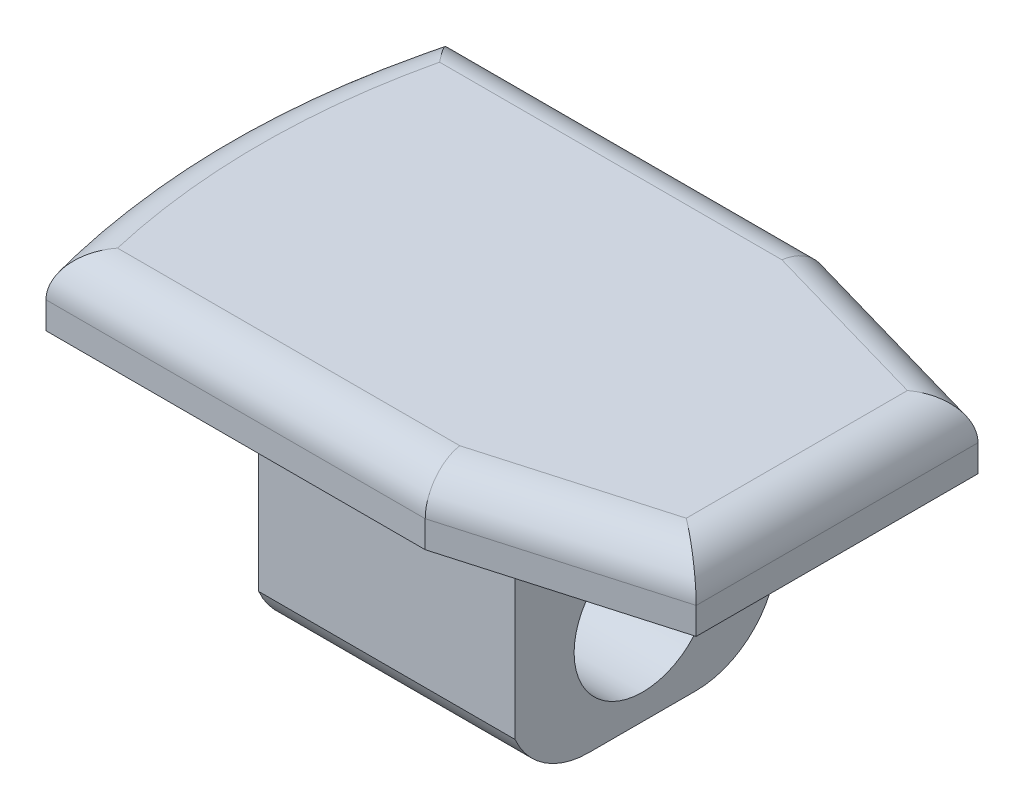
from build123d import *

# Parameters (mm, degrees)
BOSS_EXTRUDE1_DEPTH      = 2.5
BOSS_EXTRUDE2_DEPTH      = 1.5
BOSS_EXTRUDE2_DEPTH_BACK = 1.5
FILLET1_R                = 1.5
SKETCH5_W                = 9.8
SKETCH5_H                = 10
BOSS_EXTRUDE3_DEPTH      = 7.5
SKETCH6_R                = 2.55
CUT_EXTRUDE1_DEPTH       = 8
FILLET2_R                = 3
SKETCH8_R                = 3
SKETCH8_R_2              = 2.6
BOSS_EXTRUDE4_DEPTH      = 0.8
SKETCH9_W                = 0.75667274
SKETCH9_H                = 5.4
CUT_EXTRUDE3_DEPTH       = 3
SKETCH10_R               = 3
CUT_EXTRUDE4_DEPTH       = 3
CUT_EXTRUDE5_DEPTH       = 10


with BuildPart() as part:
    # Sketch1 → Boss-Extrude1 (new body)
    with BuildSketch(Plane(origin=(0, 0, 0), x_dir=(1, 0, 0), z_dir=(0, 1, 0))):
        with BuildLine():
            Line((-20.209371097, 50.622586501), (-32.257467167, 50.622586501))
            ThreePointArc((-32.257467167, 50.622586501), (-33.362688598, 43.122586501), (-32.257467167, 35.622586501))
            Line((-32.257467167, 35.622586501), (-20.209371097, 35.622586501))
            Line((-20.209371097, 35.622586501), (-12.362688598, 37.872586501))
            Line((-12.362688598, 37.872586501), (-12.362688598, 48.372586501))
            Line((-12.362688598, 48.372586501), (-20.209371097, 50.622586501))
        make_face()
        with BuildLine():
            Line((-32.257467167, 50.622586501), (-34.339530518, 50.622586501))
            ThreePointArc((-34.339530518, 50.622586501), (-35.362688598, 43.122586501), (-34.339530518, 35.622586501))
            Line((-34.339530518, 35.622586501), (-32.257467167, 35.622586501))
            ThreePointArc((-32.257467167, 35.622586501), (-33.362688598, 43.122586501), (-32.257467167, 50.622586501))
        make_face()
    extrude(amount=BOSS_EXTRUDE1_DEPTH)

    # Sketch4 → Boss-Extrude2 (add, two sides)
    with BuildSketch(Plane.XZ) as boss_extrude2_sk:
        with BuildLine():
            Line((-19.362688598, -38.122586501), (-32.877390242, -38.122586501))
            ThreePointArc((-32.877390242, -38.122586501), (-33.362688598, -43.122586501), (-32.877390242, -48.122586501))
            Line((-32.877390242, -48.122586501), (-19.362688598, -48.122586501))
            Line((-19.362688598, -48.122586501), (-19.362688598, -38.122586501))
        make_face()
    extrude(amount=BOSS_EXTRUDE2_DEPTH)
    extrude(boss_extrude2_sk.sketch, amount=-BOSS_EXTRUDE2_DEPTH_BACK)

    # Fillet1
    fillet1_edges = [part.edges().sort_by_distance(p)[0] for p in [
        (-27.274450808, 2.5, -35.622586501),
        (-16.286029847, 2.5, -36.747586501),
        (-12.362688598, 2.5, -43.122586501),
        (-16.286029847, 2.5, -49.497586501),
        (-27.274450808, 2.5, -50.622586501),
        (-35.362688598, 2.5, -43.122586501),
    ]]
    fillet(fillet1_edges, radius=FILLET1_R)

    # Sketch5 → Boss-Extrude3 (add)
    with BuildSketch(Plane.XZ.offset(1.5)):
        with Locations((-24.262688598, -43.122586501)):
            Rectangle(SKETCH5_W, SKETCH5_H)
    extrude(amount=BOSS_EXTRUDE3_DEPTH)

    # Sketch6 → Cut-Extrude1 (cut)
    with BuildSketch(Plane(origin=(-19.362688598, 0, 0), x_dir=(0, 0, -1), z_dir=(1, 0, 0))):
        with Locations((43.122586501, -5.5)):
            Circle(SKETCH6_R)
    extrude(amount=-CUT_EXTRUDE1_DEPTH, mode=Mode.SUBTRACT)

    # Fillet2
    fillet2_edges = [part.edges().sort_by_distance(p)[0] for p in [
        (-24.262688598, -9, -38.122586501),
        (-24.262688598, -9, -48.122586501),
    ]]
    fillet(fillet2_edges, radius=FILLET2_R)

    # Sketch8 → Boss-Extrude4 (add)
    with BuildSketch(Plane.ZY.offset(29.162688598)):
        with Locations((-43.122586501, -5.5)):
            Circle(SKETCH8_R)
        with Locations((-43.122586501, -5.5)):
            Circle(SKETCH8_R_2, mode=Mode.SUBTRACT)
    extrude(amount=-BOSS_EXTRUDE4_DEPTH)

    # Sketch9 → Cut-Extrude3 (cut)
    with BuildSketch(Plane(origin=(0, -9, 0), x_dir=(-1, 0, 0), z_dir=(0, -1, 0))):
        with Locations((28.784352228, 43.122586501)):
            Rectangle(SKETCH9_W, SKETCH9_H)
    extrude(amount=-CUT_EXTRUDE3_DEPTH, mode=Mode.SUBTRACT)

    # Sketch10 → Cut-Extrude4 (cut)
    with BuildSketch(Plane(origin=(-27.362688598, 0, 0), x_dir=(0, 0, -1), z_dir=(1, 0, 0))):
        with Locations((43.122586501, -5.5)):
            Circle(SKETCH10_R)
    extrude(amount=-CUT_EXTRUDE4_DEPTH, mode=Mode.SUBTRACT)

    # Sketch11 → Cut-Extrude5 (cut)
    with BuildSketch(Plane.XZ):
        with BuildLine():
            Line((-19.362688598, -38.122586501), (-32.877390242, -38.122586501))
            ThreePointArc((-32.877390242, -38.122586501), (-33.362688598, -43.122586501), (-32.877390242, -48.122586501))
            Line((-32.877390242, -48.122586501), (-19.362688598, -48.122586501))
            Line((-19.362688598, -48.122586501), (-19.362688598, -38.122586501))
        make_face()
        with BuildLine():
            Line((-19.612688598, -38.372586501), (-32.670790068, -38.372586501))
            ThreePointArc((-32.670790068, -38.372586501), (-33.112688598, -43.122586501), (-32.670790068, -47.872586501))
            Line((-32.670790068, -47.872586501), (-19.612688598, -47.872586501))
            Line((-19.612688598, -47.872586501), (-19.612688598, -38.372586501))
        make_face(mode=Mode.SUBTRACT)
    extrude(amount=CUT_EXTRUDE5_DEPTH, mode=Mode.SUBTRACT)


solid = part.part
